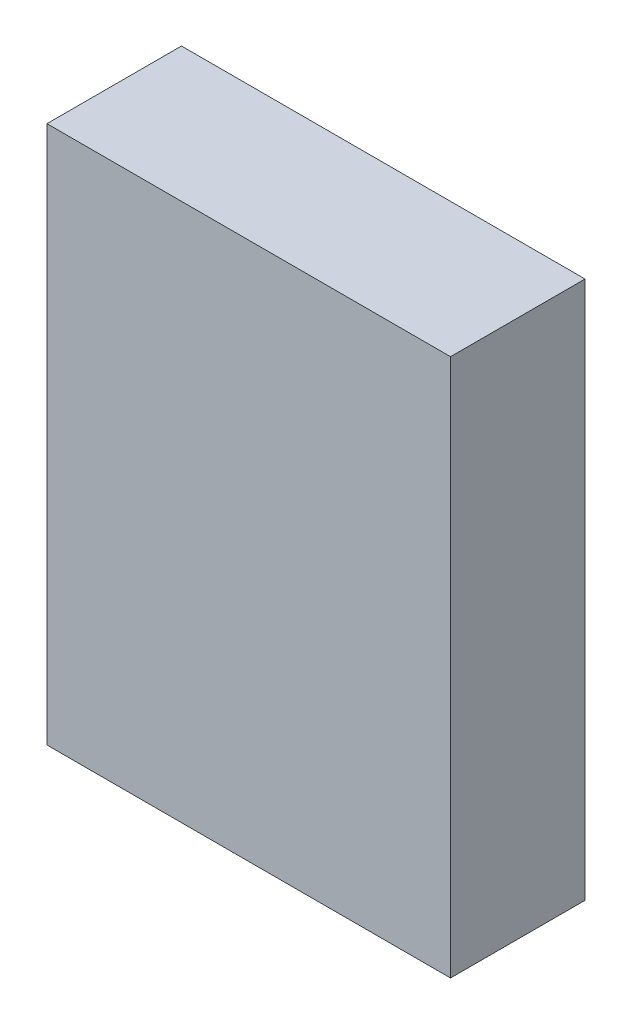
from build123d import *

# Parameters (mm, degrees)
SKETCH1_W           = 15
SKETCH1_H           = 20
BOSS_EXTRUDE1_DEPTH = 5


with BuildPart() as part:
    # Sketch1 → Boss-Extrude1 (new body)
    with BuildSketch(Plane.XY):
        Rectangle(SKETCH1_W, SKETCH1_H)
    extrude(amount=BOSS_EXTRUDE1_DEPTH)


solid = part.part
